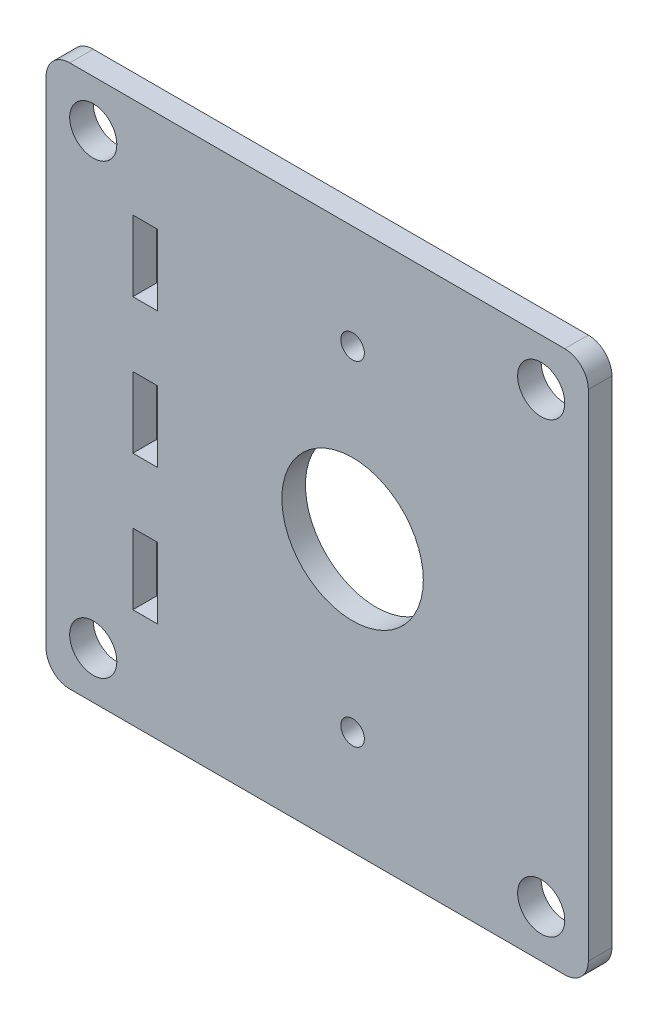
from build123d import *

# Parameters (mm, degrees)
SKETCH1_W           = 146.05
SKETCH1_H           = 146.05
SKETCH1_R           = 6.35
SKETCH1_R_2         = 19.05
SKETCH1_R_3         = 3.175
SKETCH1_W_2         = 6.604
SKETCH1_H_2         = 19.05
BOSS_EXTRUDE1_DEPTH = 3.175
FILLET1_R           = 6.35


with BuildPart() as part:
    # Sketch1 → Boss-Extrude1 (new body, symmetric)
    with BuildSketch(Plane.XY):
        with Locations((-9.525, 0)):
            Rectangle(SKETCH1_W, SKETCH1_H)
        with Locations((50.8, 60.325)):
            Circle(SKETCH1_R, mode=Mode.SUBTRACT)
        with Locations((50.8, -60.325)):
            Circle(SKETCH1_R, mode=Mode.SUBTRACT)
        Circle(SKETCH1_R_2, mode=Mode.SUBTRACT)
        with Locations((0, 45)):
            Circle(SKETCH1_R_3, mode=Mode.SUBTRACT)
        with Locations((0, -45)):
            Circle(SKETCH1_R_3, mode=Mode.SUBTRACT)
        with Locations((-69.85, 60.325)):
            Circle(SKETCH1_R, mode=Mode.SUBTRACT)
        with Locations((-69.85, -60.325)):
            Circle(SKETCH1_R, mode=Mode.SUBTRACT)
        with Locations((-55.88, 0)):
            Rectangle(SKETCH1_W_2, SKETCH1_H_2, mode=Mode.SUBTRACT)
        with Locations((-55.88, 36.5125)):
            Rectangle(SKETCH1_W_2, SKETCH1_H_2, mode=Mode.SUBTRACT)
        with Locations((-55.88, -36.5125)):
            Rectangle(SKETCH1_W_2, SKETCH1_H_2, mode=Mode.SUBTRACT)
    extrude(amount=BOSS_EXTRUDE1_DEPTH, both=True)

    # Fillet1
    fillet1_edges = [part.edges().sort_by_distance(p)[0] for p in [
        (-82.55, 73.025, 0),
        (63.5, 73.025, 0),
        (63.5, -73.025, 0),
        (-82.55, -73.025, 0),
    ]]
    fillet(fillet1_edges, radius=FILLET1_R)


solid = part.part
